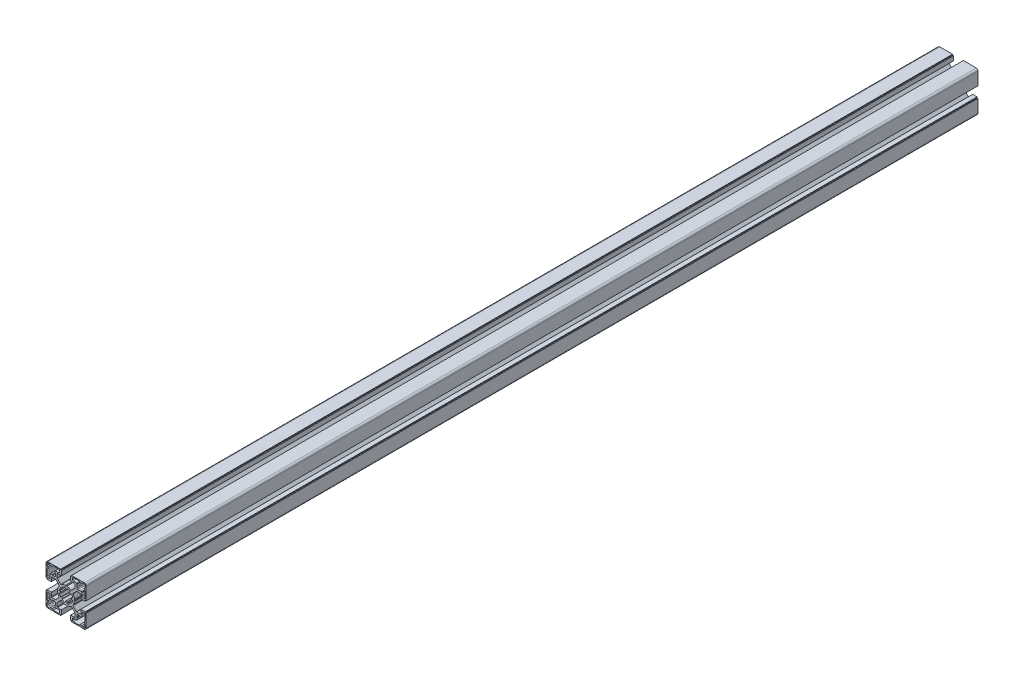
from build123d import *

# Parameters (mm, degrees)
EXTRUDE_1_DEPTH = 1000


with BuildPart() as part:
    # 草图1 → 拉伸1 (new body)
    with BuildSketch(Plane.XY):
        with BuildLine():
            Line((32.913692814, 48.527108363), (33.379387937, 47.720500749))
            ThreePointArc((33.379387937, 47.720500749), (32.846656731, 45.294128985), (31.703110488, 43.088820737))
            ThreePointArc((31.703110488, 43.088820737), (31.61501252, 42.758675306), (31.759526449, 42.449041682))
            Line((31.759526449, 42.449041682), (35.535013158, 38.673554973))
            ThreePointArc((35.535013158, 38.673554973), (35.697224832, 38.565168597), (35.888566548, 38.527108363))
            Line((35.888566548, 38.527108363), (39.913692815, 38.527108363))
            ThreePointArc((39.913692815, 38.527108363), (40.267246205, 38.673554973), (40.413692815, 39.027108363))
            Line((40.413692815, 39.027108363), (40.413692815, 43.427108363))
            Line((40.413692815, 43.427108363), (45.413692815, 43.427108363))
            Line((45.413692815, 43.427108363), (45.413692815, 42.427108363))
            Line((45.413692815, 42.427108363), (46.413692815, 42.427108363))
            Line((46.413692815, 42.427108363), (46.413692815, 28.027108363))
            ThreePointArc((46.413692815, 28.027108363), (45.827906377, 26.612894801), (44.413692815, 26.027108363))
            Line((44.413692815, 26.027108363), (30.013692814, 26.027108363))
            Line((30.013692814, 26.027108363), (30.013692814, 27.027108363))
            Line((30.013692814, 27.027108363), (29.013692814, 27.027108363))
            Line((29.013692814, 27.027108363), (29.013692814, 32.027108363))
            Line((29.013692814, 32.027108363), (33.413692814, 32.027108363))
            ThreePointArc((33.413692814, 32.027108363), (33.767246205, 32.173554972), (33.913692814, 32.527108363))
            Line((33.913692814, 32.527108363), (33.913692814, 36.552234629))
            ThreePointArc((33.913692814, 36.552234629), (33.875632581, 36.743576345), (33.767246205, 36.90578802))
            Line((33.767246205, 36.90578802), (29.991759496, 40.681274729))
            ThreePointArc((29.991759496, 40.681274729), (29.682125871, 40.825788657), (29.351980441, 40.737690689))
            ThreePointArc((29.351980441, 40.737690689), (27.146672193, 39.594144446), (24.720300428, 39.06141324))
            Line((24.720300428, 39.06141324), (23.913692814, 39.527108363))
            Line((23.913692814, 39.527108363), (23.107085201, 39.06141324))
            ThreePointArc((23.107085201, 39.06141324), (20.680713436, 39.594144446), (18.475405188, 40.737690689))
            ThreePointArc((18.475405188, 40.737690689), (18.145259758, 40.825788657), (17.835626133, 40.681274729))
            Line((17.835626133, 40.681274729), (14.060139424, 36.90578802))
            ThreePointArc((14.060139424, 36.90578802), (13.951753048, 36.743576345), (13.913692814, 36.552234629))
            Line((13.913692814, 36.552234629), (13.913692814, 32.527108363))
            ThreePointArc((13.913692814, 32.527108363), (14.060139424, 32.173554972), (14.413692814, 32.027108363))
            Line((14.413692814, 32.027108363), (18.813692815, 32.027108363))
            Line((18.813692815, 32.027108363), (18.813692815, 27.027108363))
            Line((18.813692815, 27.027108363), (17.813692815, 27.027108363))
            Line((17.813692815, 27.027108363), (17.813692815, 26.027108363))
            Line((17.813692815, 26.027108363), (3.413692814, 26.027108363))
            ThreePointArc((3.413692814, 26.027108363), (1.999479252, 26.6128948), (1.413692814, 28.027108363))
            Line((1.413692814, 28.027108363), (1.413692814, 42.427108363))
            Line((1.413692814, 42.427108363), (2.413692814, 42.427108363))
            Line((2.413692814, 42.427108363), (2.413692814, 43.427108363))
            Line((2.413692814, 43.427108363), (7.413692814, 43.427108363))
            Line((7.413692814, 43.427108363), (7.413692814, 39.027108363))
            ThreePointArc((7.413692814, 39.027108363), (7.560139424, 38.673554972), (7.913692814, 38.527108363))
            Line((7.913692814, 38.527108363), (11.93881908, 38.527108363))
            ThreePointArc((11.93881908, 38.527108363), (12.130160796, 38.565168597), (12.292372471, 38.673554972))
            Line((12.292372471, 38.673554972), (16.06785918, 42.449041682))
            ThreePointArc((16.06785918, 42.449041682), (16.212373108, 42.758675306), (16.124275141, 43.088820737))
            ThreePointArc((16.124275141, 43.088820737), (14.980728897, 45.294128984), (14.447997691, 47.720500749))
            Line((14.447997691, 47.720500749), (14.913692814, 48.527108363))
            Line((14.913692814, 48.527108363), (14.447997691, 49.333715976))
            ThreePointArc((14.447997691, 49.333715976), (14.980728897, 51.760087741), (16.124275141, 53.96539599))
            ThreePointArc((16.124275141, 53.96539599), (16.212373108, 54.29554142), (16.06785918, 54.605175045))
            Line((16.06785918, 54.605175045), (12.292372471, 58.380661754))
            ThreePointArc((12.292372471, 58.380661754), (12.130160797, 58.489048129), (11.93881908, 58.527108363))
            Line((11.93881908, 58.527108363), (7.913692814, 58.527108363))
            ThreePointArc((7.913692814, 58.527108363), (7.560139424, 58.380661754), (7.413692814, 58.027108363))
            Line((7.413692814, 58.027108363), (7.413692814, 53.627108363))
            Line((7.413692814, 53.627108363), (2.413692814, 53.627108363))
            Line((2.413692814, 53.627108363), (2.413692814, 54.627108363))
            Line((2.413692814, 54.627108363), (1.413692814, 54.627108363))
            Line((1.413692814, 54.627108363), (1.413692814, 69.027108363))
            ThreePointArc((1.413692814, 69.027108363), (1.999479252, 70.441321926), (3.413692814, 71.027108363))
            Line((3.413692814, 71.027108363), (17.813692814, 71.027108363))
            Line((17.813692814, 71.027108363), (17.813692814, 70.027108363))
            Line((17.813692814, 70.027108363), (18.813692815, 70.027108363))
            Line((18.813692815, 70.027108363), (18.813692815, 65.027108363))
            Line((18.813692815, 65.027108363), (14.413692814, 65.027108363))
            ThreePointArc((14.413692814, 65.027108363), (14.060139424, 64.880661754), (13.913692814, 64.527108363))
            Line((13.913692814, 64.527108363), (13.913692814, 60.501982097))
            ThreePointArc((13.913692814, 60.501982097), (13.951753048, 60.310640381), (14.060139424, 60.148428707))
            Line((14.060139424, 60.148428707), (17.835626133, 56.372941998))
            ThreePointArc((17.835626133, 56.372941998), (18.145259758, 56.228428069), (18.475405188, 56.316526037))
            ThreePointArc((18.475405188, 56.316526037), (20.680713436, 57.46007228), (23.107085201, 57.992803486))
            Line((23.107085201, 57.992803486), (23.913692814, 57.527108363))
            Line((23.913692814, 57.527108363), (24.720300428, 57.992803486))
            ThreePointArc((24.720300428, 57.992803486), (27.146672193, 57.46007228), (29.351980441, 56.316526037))
            ThreePointArc((29.351980441, 56.316526037), (29.682125871, 56.228428069), (29.991759496, 56.372941998))
            Line((29.991759496, 56.372941998), (33.767246205, 60.148428707))
            ThreePointArc((33.767246205, 60.148428707), (33.875632581, 60.310640381), (33.913692814, 60.501982097))
            Line((33.913692814, 60.501982097), (33.913692814, 64.527108363))
            ThreePointArc((33.913692814, 64.527108363), (33.767246205, 64.880661754), (33.413692814, 65.027108363))
            Line((33.413692814, 65.027108363), (29.013692814, 65.027108363))
            Line((29.013692814, 65.027108363), (29.013692814, 70.027108363))
            Line((29.013692814, 70.027108363), (30.013692814, 70.027108363))
            Line((30.013692814, 70.027108363), (30.013692814, 71.027108363))
            Line((30.013692814, 71.027108363), (44.413692815, 71.027108363))
            ThreePointArc((44.413692815, 71.027108363), (45.827906377, 70.441321926), (46.413692815, 69.027108363))
            Line((46.413692815, 69.027108363), (46.413692815, 54.627108363))
            Line((46.413692815, 54.627108363), (45.413692814, 54.627108363))
            Line((45.413692814, 54.627108363), (45.413692814, 53.627108363))
            Line((45.413692814, 53.627108363), (40.413692814, 53.627108363))
            Line((40.413692814, 53.627108363), (40.413692814, 58.027108363))
            ThreePointArc((40.413692814, 58.027108363), (40.267246205, 58.380661754), (39.913692814, 58.527108363))
            Line((39.913692814, 58.527108363), (35.888566548, 58.527108363))
            ThreePointArc((35.888566548, 58.527108363), (35.697224832, 58.489048129), (35.535013158, 58.380661754))
            Line((35.535013158, 58.380661754), (31.759526449, 54.605175045))
            ThreePointArc((31.759526449, 54.605175045), (31.61501252, 54.29554142), (31.703110488, 53.96539599))
            ThreePointArc((31.703110488, 53.96539599), (32.846656731, 51.760087741), (33.379387937, 49.333715976))
            Line((33.379387937, 49.333715976), (32.913692814, 48.527108363))
        make_face()
        with BuildLine():
            Line((31.349529275, 47.548161921), (29.862361982, 47.74395121))
            ThreePointArc((29.862361982, 47.74395121), (29.913692814, 48.527108363), (29.862361982, 49.310265516))
            Line((29.862361982, 49.310265516), (31.349529275, 49.506054805))
            ThreePointArc((31.349529275, 49.506054805), (30.842789308, 51.397234106), (29.863842867, 53.092819081))
            Line((29.863842867, 53.092819081), (28.673812856, 52.179676937))
            ThreePointArc((28.673812856, 52.179676937), (28.156333501, 52.76974905), (27.566261388, 53.287228405))
            Line((27.566261388, 53.287228405), (28.479403532, 54.477258415))
            ThreePointArc((28.479403532, 54.477258415), (26.783818557, 55.456204857), (24.892639256, 55.962944824))
            Line((24.892639256, 55.962944824), (24.696849968, 54.475777531))
            ThreePointArc((24.696849968, 54.475777531), (23.913692814, 54.527108363), (23.130535661, 54.475777531))
            Line((23.130535661, 54.475777531), (22.934746373, 55.962944824))
            ThreePointArc((22.934746373, 55.962944824), (21.043567072, 55.456204857), (19.347982097, 54.477258415))
            Line((19.347982097, 54.477258415), (20.26112424, 53.287228405))
            ThreePointArc((20.26112424, 53.287228405), (19.671052127, 52.76974905), (19.153572773, 52.179676937))
            Line((19.153572773, 52.179676937), (17.963542762, 53.092819081))
            ThreePointArc((17.963542762, 53.092819081), (16.98459632, 51.397234106), (16.477856354, 49.506054805))
            Line((16.477856354, 49.506054805), (17.965023646, 49.310265516))
            ThreePointArc((17.965023646, 49.310265516), (17.913692814, 48.527108363), (17.965023646, 47.74395121))
            Line((17.965023646, 47.74395121), (16.477856354, 47.548161921))
            ThreePointArc((16.477856354, 47.548161921), (16.98459632, 45.65698262), (17.963542762, 43.961397645))
            Line((17.963542762, 43.961397645), (19.153572773, 44.874539789))
            ThreePointArc((19.153572773, 44.874539789), (19.671052127, 44.284467676), (20.26112424, 43.766988321))
            Line((20.26112424, 43.766988321), (19.347982097, 42.576958311))
            ThreePointArc((19.347982097, 42.576958311), (21.043567072, 41.598011869), (22.934746373, 41.091271903))
            Line((22.934746373, 41.091271903), (23.130535661, 42.578439195))
            ThreePointArc((23.130535661, 42.578439195), (23.913692814, 42.527108363), (24.696849968, 42.578439195))
            Line((24.696849968, 42.578439195), (24.892639256, 41.091271903))
            ThreePointArc((24.892639256, 41.091271903), (26.783818557, 41.598011869), (28.479403532, 42.576958311))
            Line((28.479403532, 42.576958311), (27.566261388, 43.766988321))
            ThreePointArc((27.566261388, 43.766988321), (28.156333501, 44.284467676), (28.673812856, 44.874539789))
            Line((28.673812856, 44.874539789), (29.863842867, 43.961397645))
            ThreePointArc((29.863842867, 43.961397645), (30.842789308, 45.65698262), (31.349529275, 47.548161921))
        make_face(mode=Mode.SUBTRACT)
        with BuildLine():
            Line((11.913692814, 66.527108364), (15.813692814, 66.527108364))
            ThreePointArc((15.813692814, 66.527108364), (16.520799595, 66.820001582), (16.813692814, 67.527108364))
            Line((16.813692814, 67.527108364), (16.813692814, 69.027108363))
            ThreePointArc((16.813692814, 69.027108363), (16.520799595, 69.734215144), (15.813692814, 70.027108363))
            Line((15.813692814, 70.027108363), (9.413692815, 70.027108363))
            Line((9.413692815, 70.027108363), (8.413692814, 69.027108363))
            Line((8.413692814, 69.027108363), (6.413692814, 69.027108363))
            Line((6.413692814, 69.027108363), (5.413692814, 70.027108363))
            Line((5.413692814, 70.027108363), (3.413692814, 70.027108363))
            ThreePointArc((3.413692814, 70.027108363), (2.706586033, 69.734215144), (2.413692814, 69.027108363))
            Line((2.413692814, 69.027108363), (2.413692814, 67.027108363))
            Line((2.413692814, 67.027108363), (3.413692814, 66.027108363))
            Line((3.413692814, 66.027108363), (3.413692814, 64.027108363))
            Line((3.413692814, 64.027108363), (2.413692814, 63.027108363))
            Line((2.413692814, 63.027108363), (2.413692814, 56.627108364))
            ThreePointArc((2.413692814, 56.627108364), (2.706586033, 55.920001582), (3.413692814, 55.627108364))
            Line((3.413692814, 55.627108364), (4.913692814, 55.627108364))
            ThreePointArc((4.913692814, 55.627108364), (5.620799595, 55.920001582), (5.913692814, 56.627108364))
            Line((5.913692814, 56.627108364), (5.913692814, 60.527108363))
            Line((5.913692814, 60.527108363), (6.413692814, 61.027108363))
            Line((6.413692814, 61.027108363), (8.413692814, 61.027108363))
            Line((8.413692814, 61.027108363), (8.913692814, 60.527108363))
            Line((8.913692814, 60.527108363), (10.913692814, 60.527108363))
            ThreePointArc((10.913692814, 60.527108363), (11.620799595, 60.820001582), (11.913692814, 61.527108363))
            Line((11.913692814, 61.527108363), (11.913692814, 63.527108363))
            Line((11.913692814, 63.527108363), (11.413692814, 64.027108363))
            Line((11.413692814, 64.027108363), (11.413692814, 66.027108363))
            Line((11.413692814, 66.027108363), (11.913692814, 66.527108364))
        make_face(mode=Mode.SUBTRACT)
        with BuildLine():
            Line((42.913692815, 55.627108364), (44.413692815, 55.627108364))
            ThreePointArc((44.413692815, 55.627108364), (45.120799596, 55.920001582), (45.413692815, 56.627108364))
            Line((45.413692815, 56.627108364), (45.413692815, 63.027108363))
            Line((45.413692815, 63.027108363), (44.413692815, 64.027108363))
            Line((44.413692815, 64.027108363), (44.413692815, 66.027108363))
            Line((44.413692815, 66.027108363), (45.413692815, 67.027108363))
            Line((45.413692815, 67.027108363), (45.413692815, 69.027108363))
            ThreePointArc((45.413692815, 69.027108363), (45.120799596, 69.734215144), (44.413692815, 70.027108363))
            Line((44.413692815, 70.027108363), (42.413692815, 70.027108363))
            Line((42.413692815, 70.027108363), (41.413692814, 69.027108363))
            Line((41.413692814, 69.027108363), (39.413692814, 69.027108363))
            Line((39.413692814, 69.027108363), (38.413692814, 70.027108363))
            Line((38.413692814, 70.027108363), (32.013692815, 70.027108363))
            ThreePointArc((32.013692815, 70.027108363), (31.306586034, 69.734215145), (31.013692815, 69.027108363))
            Line((31.013692815, 69.027108363), (31.013692815, 67.527108364))
            ThreePointArc((31.013692815, 67.527108364), (31.306586034, 66.820001582), (32.013692815, 66.527108364))
            Line((32.013692815, 66.527108364), (35.913692815, 66.527108364))
            Line((35.913692815, 66.527108364), (36.413692815, 66.027108363))
            Line((36.413692815, 66.027108363), (36.413692815, 64.027108363))
            Line((36.413692815, 64.027108363), (35.913692815, 63.527108363))
            Line((35.913692815, 63.527108363), (35.913692815, 61.527108363))
            ThreePointArc((35.913692815, 61.527108363), (36.206586034, 60.820001582), (36.913692815, 60.527108363))
            Line((36.913692815, 60.527108363), (38.913692815, 60.527108363))
            Line((38.913692815, 60.527108363), (39.413692815, 61.027108363))
            Line((39.413692815, 61.027108363), (41.413692815, 61.027108363))
            Line((41.413692815, 61.027108363), (41.913692815, 60.527108363))
            Line((41.913692815, 60.527108363), (41.913692815, 56.627108364))
            ThreePointArc((41.913692815, 56.627108364), (42.206586034, 55.920001582), (42.913692815, 55.627108364))
        make_face(mode=Mode.SUBTRACT)
        with BuildLine():
            Line((4.913692814, 41.427108363), (3.413692814, 41.427108363))
            ThreePointArc((3.413692814, 41.427108363), (2.706586033, 41.134215144), (2.413692814, 40.427108363))
            Line((2.413692814, 40.427108363), (2.413692814, 34.027108363))
            Line((2.413692814, 34.027108363), (3.413692814, 33.027108363))
            Line((3.413692814, 33.027108363), (3.413692814, 31.027108363))
            Line((3.413692814, 31.027108363), (2.413692814, 30.027108363))
            Line((2.413692814, 30.027108363), (2.413692814, 28.027108363))
            ThreePointArc((2.413692814, 28.027108363), (2.706586033, 27.320001582), (3.413692814, 27.027108363))
            Line((3.413692814, 27.027108363), (5.413692814, 27.027108363))
            Line((5.413692814, 27.027108363), (6.413692814, 28.027108363))
            Line((6.413692814, 28.027108363), (8.413692814, 28.027108363))
            Line((8.413692814, 28.027108363), (9.413692815, 27.027108363))
            Line((9.413692815, 27.027108363), (15.813692814, 27.027108363))
            ThreePointArc((15.813692814, 27.027108363), (16.520799595, 27.320001582), (16.813692814, 28.027108363))
            Line((16.813692814, 28.027108363), (16.813692814, 29.527108363))
            ThreePointArc((16.813692814, 29.527108363), (16.520799595, 30.234215144), (15.813692814, 30.527108363))
            Line((15.813692814, 30.527108363), (11.913692814, 30.527108363))
            Line((11.913692814, 30.527108363), (11.413692814, 31.027108363))
            Line((11.413692814, 31.027108363), (11.413692814, 33.027108363))
            Line((11.413692814, 33.027108363), (11.913692814, 33.527108363))
            Line((11.913692814, 33.527108363), (11.913692814, 35.527108363))
            ThreePointArc((11.913692814, 35.527108363), (11.620799595, 36.234215144), (10.913692814, 36.527108363))
            Line((10.913692814, 36.527108363), (8.913692814, 36.527108363))
            Line((8.913692814, 36.527108363), (8.413692814, 36.027108363))
            Line((8.413692814, 36.027108363), (6.413692814, 36.027108363))
            Line((6.413692814, 36.027108363), (5.913692814, 36.527108363))
            Line((5.913692814, 36.527108363), (5.913692814, 40.427108363))
            ThreePointArc((5.913692814, 40.427108363), (5.620799595, 41.134215144), (4.913692814, 41.427108363))
        make_face(mode=Mode.SUBTRACT)
        with BuildLine():
            Line((45.413692815, 34.027108363), (45.413692815, 40.427108363))
            ThreePointArc((45.413692815, 40.427108363), (45.120799596, 41.134215144), (44.413692815, 41.427108363))
            Line((44.413692815, 41.427108363), (42.913692815, 41.427108363))
            ThreePointArc((42.913692815, 41.427108363), (42.206586034, 41.134215144), (41.913692815, 40.427108363))
            Line((41.913692815, 40.427108363), (41.913692815, 36.527108363))
            Line((41.913692815, 36.527108363), (41.413692815, 36.027108363))
            Line((41.413692815, 36.027108363), (39.413692815, 36.027108363))
            Line((39.413692815, 36.027108363), (38.913692815, 36.527108363))
            Line((38.913692815, 36.527108363), (36.913692815, 36.527108363))
            ThreePointArc((36.913692815, 36.527108363), (36.206586034, 36.234215144), (35.913692815, 35.527108363))
            Line((35.913692815, 35.527108363), (35.913692815, 33.527108363))
            Line((35.913692815, 33.527108363), (36.413692815, 33.027108363))
            Line((36.413692815, 33.027108363), (36.413692815, 31.027108363))
            Line((36.413692815, 31.027108363), (35.913692815, 30.527108363))
            Line((35.913692815, 30.527108363), (32.013692815, 30.527108363))
            ThreePointArc((32.013692815, 30.527108363), (31.306586034, 30.234215144), (31.013692815, 29.527108363))
            Line((31.013692815, 29.527108363), (31.013692815, 28.027108363))
            ThreePointArc((31.013692815, 28.027108363), (31.306586034, 27.320001582), (32.013692815, 27.027108363))
            Line((32.013692815, 27.027108363), (38.413692814, 27.027108363))
            Line((38.413692814, 27.027108363), (39.413692814, 28.027108363))
            Line((39.413692814, 28.027108363), (41.413692814, 28.027108363))
            Line((41.413692814, 28.027108363), (42.413692815, 27.027108363))
            Line((42.413692815, 27.027108363), (44.413692815, 27.027108363))
            ThreePointArc((44.413692815, 27.027108363), (45.120799596, 27.320001582), (45.413692815, 28.027108363))
            Line((45.413692815, 28.027108363), (45.413692815, 30.027108363))
            Line((45.413692815, 30.027108363), (44.413692814, 31.027108363))
            Line((44.413692814, 31.027108363), (44.413692814, 33.027108363))
            Line((44.413692814, 33.027108363), (45.413692815, 34.027108363))
        make_face(mode=Mode.SUBTRACT)
    extrude(amount=EXTRUDE_1_DEPTH)


solid = part.part
